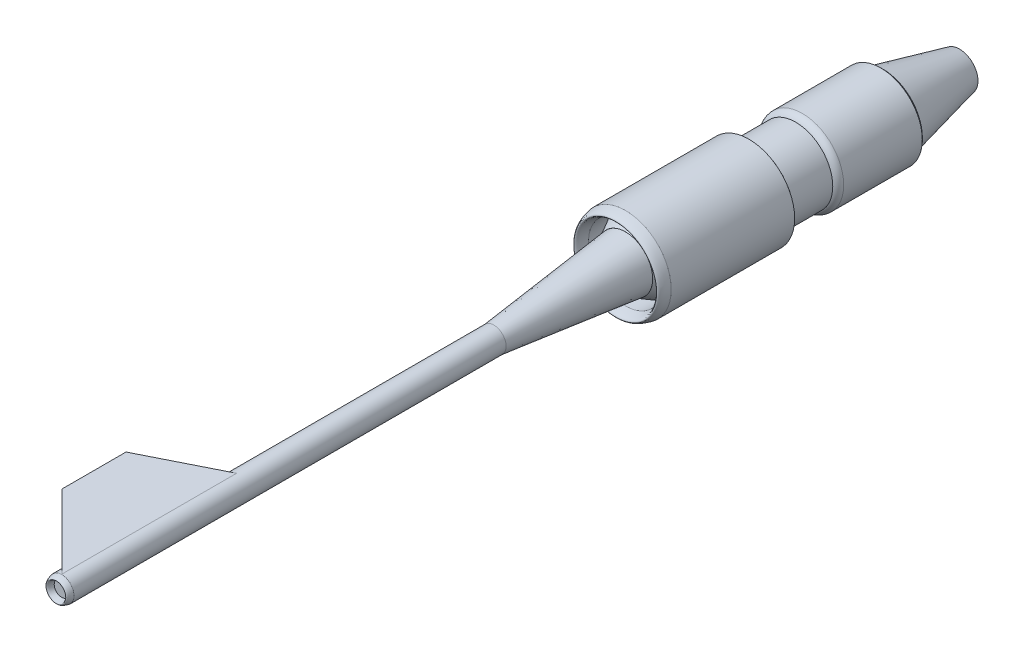
from build123d import *

# Parameters (mm, degrees)
SKETCH1_R           = 416.25
SKETCH1_R_2         = 337.5
BOSS_EXTRUDE1_DEPTH = 1125
SKETCH5_R           = 112.5
BOSS_EXTRUDE2_DEPTH = 3937.5
SKETCH15_R          = 337.5
BOSS_EXTRUDE5_DEPTH = 486
SKETCH16_R          = 376.875
BOSS_EXTRUDE6_DEPTH = 716
BOSS_EXTRUDE7_DEPTH = 50


with BuildPart() as part:
    # Sketch1 → Boss-Extrude1 (new body)
    with BuildSketch(Plane.XY):
        Circle(SKETCH1_R)
        Circle(SKETCH1_R_2, mode=Mode.SUBTRACT)
    extrude(amount=-BOSS_EXTRUDE1_DEPTH)

    # Sketch2 → Revolve1 (revolve)
    with BuildSketch(Plane(origin=(0, 0, 0), x_dir=(0, 0, -1), z_dir=(1, 0, 0))):
        with BuildLine():
            Line((0, 416.25), (0, 337.5))
            add(Edge.make_bspline(
                [(0, 337.5), (-180, 376.875), (0, 416.25)],
                knots=[0, 0, 0, 1, 1, 1], degree=2))
        make_face()
    revolve(axis=Axis((0, 0, 0), (0, 0, -1)))

    # Sketch18 → Revolve6 (revolve)
    with BuildSketch(Plane(origin=(0, 0, 0), x_dir=(0, 0, -1), z_dir=(1, 0, 0)), mode=Mode.PRIVATE) as revolve6_sk:
        Polygon((0, 247.5), (306.632414301, 416.25), (306.632414301, 247.5), align=None)
    revolve(revolve6_sk.sketch.rotate(Axis((0, 0, 0), (0, 0, -1)), 90), axis=Axis((0, 0, 0), (0, 0, -1)))



with BuildPart() as body_2:
    # Sketch4 → Revolve2 (revolve)
    with BuildSketch(Plane(origin=(0, 0, 0), x_dir=(1, 0, 0), z_dir=(0, 1, 0)), mode=Mode.PRIVATE) as revolve2_sk:
        Polygon((0, 0), (0, -1200), (112.5, -1200), (247.5, 0), align=None)
    revolve(revolve2_sk.sketch.rotate(Axis((0, 0, 0), (0, 0, 1)), 180), axis=Axis((0, 0, 0), (0, 0, 1)))

    # Sketch5 → Boss-Extrude2 (add)
    with BuildSketch(Plane.XY.offset(1200)):
        Circle(SKETCH5_R)
    extrude(amount=BOSS_EXTRUDE2_DEPTH)

    # Sketch14 → Revolve4 (revolve)
    with BuildSketch(Plane(origin=(0, 0, 0), x_dir=(0, 0, -1), z_dir=(1, 0, 0))):
        with BuildLine():
            add(Edge.make_bspline(
                [(-5137.5, 67.5), (-5237.5, 90), (-5137.5, 112.5)],
                knots=[0, 0, 0, 1, 1, 1], degree=2))
            Line((-5137.5, 112.5), (-5137.5, 67.5))
        make_face()
    revolve(axis=Axis((0, 0, 5137.5), (0, 0, 1)))

    # Sketch22 → Boss-Extrude7 (add)
    with BuildSketch(Plane(origin=(0, 112.486092048, 0), x_dir=(1, 0, 0), z_dir=(0, 1, 0))):
        Polygon((1.768925034, -5137.5), (1.768925034, -3540), (-673.231074966, -3877.5), (-673.231074966, -4462.5), align=None)
    extrude(amount=-BOSS_EXTRUDE7_DEPTH)


with BuildPart() as body_3:
    # Sketch15 → Boss-Extrude5 (new body)
    with BuildSketch(Plane(origin=(0, 0, -1125), x_dir=(-1, 0, 0), z_dir=(0, 0, -1))):
        with Locations(Location((0, 0, 0), (0, 0, 180))):
            Circle(SKETCH15_R)
    extrude(amount=BOSS_EXTRUDE5_DEPTH)

    # Sketch16 → Boss-Extrude6 (add)
    with BuildSketch(Plane(origin=(0, 0, -1611), x_dir=(-1, 0, 0), z_dir=(0, 0, -1))):
        with Locations(Location((0, 0, 0), (0, 0, 180))):
            Circle(SKETCH16_R)
    extrude(amount=BOSS_EXTRUDE6_DEPTH)

    # Sketch17 → Revolve5 (revolve)
    with BuildSketch(Plane(origin=(0, 0, 0), x_dir=(0, 0, -1), z_dir=(1, 0, 0)), mode=Mode.PRIVATE) as revolve5_sk:
        Polygon((2327, 0), (3043, 0), (3043, 168.75), (2327, 337.5), align=None)
    revolve(revolve5_sk.sketch.rotate(Axis((0, 0, -2327), (0, 0, -1)), 270), axis=Axis((0, 0, -2327), (0, 0, -1)))

    # Sketch19 → Revolve9 (revolve)
    with BuildSketch(Plane(origin=(0, 0, 0), x_dir=(0, 0, -1), z_dir=(1, 0, 0)), mode=Mode.PRIVATE) as revolve9_sk:
        with BuildLine():
            Line((1611, 337.5), (1551, 337.5))
            ThreePointArc((1551, 337.5), (1575.706535425, 365.253731733), (1611, 376.875))
            Line((1611, 376.875), (1611, 337.5))
        make_face()
    revolve(revolve9_sk.sketch.rotate(Axis((0, 0, -1611), (0, 0, 1)), 90), axis=Axis((0, 0, -1611), (0, 0, 1)))


with BuildPart() as part_1:
    add(part.part)

    add(body_3.part)  # Revolve11 merges body 3
    # Sketch20 → Revolve11 (revolve)
    with BuildSketch(Plane(origin=(0, 0, 0), x_dir=(0, 0, -1), z_dir=(1, 0, 0)), mode=Mode.PRIVATE) as revolve11_sk:
        with BuildLine():
            Line((1125, 337.5), (1125, 416.25))
            add(Edge.make_bspline(
                [(1155, 337.5), (1155, 382.589285714), (1125, 416.25)],
                knots=[0, 0, 0, 1, 1, 1], degree=2, weights=[1, 0.806097206, 1]))
            Line((1155, 337.5), (1125, 337.5))
        make_face()
    revolve(revolve11_sk.sketch.rotate(Axis((0, 0, -1125), (0, 0, -1)), 90), axis=Axis((0, 0, -1125), (0, 0, -1)))

    # Sketch21 → Revolve12 (revolve)
    with BuildSketch(Plane(origin=(0, 0, 0), x_dir=(0, 0, -1), z_dir=(1, 0, 0)), mode=Mode.PRIVATE) as revolve12_sk:
        with BuildLine():
            Line((2327, 337.5), (2327, 376.875))
            add(Edge.make_bspline(
                [(2327, 376.875), (2356.199972531, 357.1875), (2356.199972531, 330.618023234)],
                knots=[0, 0, 0, 1, 1, 1], degree=2, weights=[1, 0.829833158, 1]))
            Line((2356.199972531, 330.618023234), (2327, 337.5))
        make_face()
    revolve(revolve12_sk.sketch.rotate(Axis((0, 0, -2327), (0, 0, -1)), 90), axis=Axis((0, 0, -2327), (0, 0, -1)))


solid = Compound([body_2.part, part_1.part])
